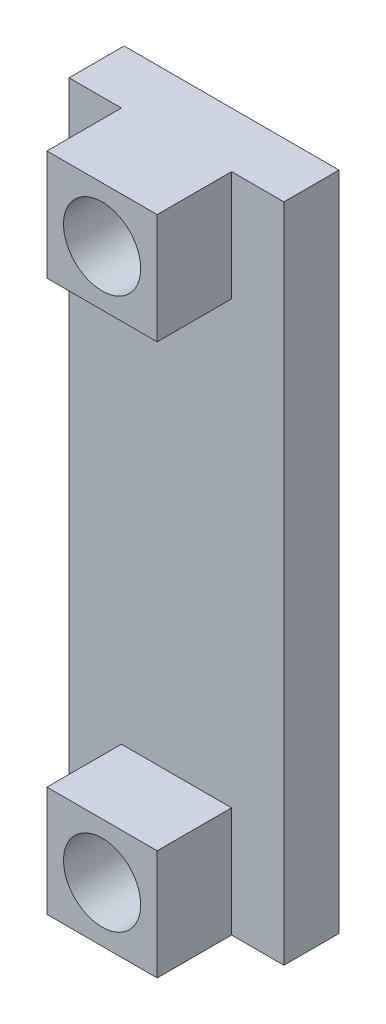
from build123d import *

# Parameters (mm, degrees)
SKETCH1_W           = 9.906
SKETCH1_H           = 30.48
BOSS_EXTRUDE1_DEPTH = 2.54
SKETCH2_W           = 5.08
SKETCH2_H           = 5.08
BOSS_EXTRUDE2_DEPTH = 3.429
SKETCH3_R           = 1.778
CUT_EXTRUDE1_DEPTH  = 12.7


with BuildPart() as part:
    # Sketch1 → Boss-Extrude1 (new body)
    with BuildSketch(Plane.XY):
        with Locations((-4.953, -15.24)):
            Rectangle(SKETCH1_W, SKETCH1_H)
    extrude(amount=BOSS_EXTRUDE1_DEPTH)

    # Sketch2 → Boss-Extrude2 (add)
    with BuildSketch(Plane.XY.offset(2.54)):
        with Locations((-4.953, -2.54)):
            Rectangle(SKETCH2_W, SKETCH2_H)
        with Locations((-4.953, -27.94)):
            Rectangle(SKETCH2_W, SKETCH2_H)
    extrude(amount=BOSS_EXTRUDE2_DEPTH)

    # Sketch3 → Cut-Extrude1 (cut)
    with BuildSketch(Plane.XY.offset(5.969)):
        with Locations((-4.953, -27.94)):
            Circle(SKETCH3_R)
        with Locations((-4.953, -2.54)):
            Circle(SKETCH3_R)
    extrude(amount=-CUT_EXTRUDE1_DEPTH, mode=Mode.SUBTRACT)


solid = part.part
